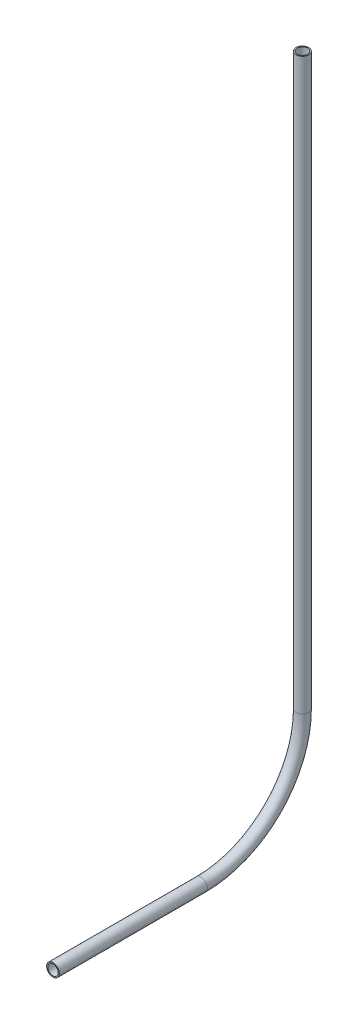
from build123d import *

# Parameters (mm, degrees)
SKETCH11_R                = 3.175
SKETCH11_R_2              = 2.6162
PIPE_0_5_SCH_40_1_DEPTH   = 74.183620327
SKETCH11_ON_SEGMENT_2_R   = 3.175
SKETCH11_ON_SEGMENT_2_R_2 = 2.6162
PIPE_0_5_SCH_40_1_2_ANGLE = 90
SKETCH11_ON_SEGMENT_3_R   = 3.175
SKETCH11_ON_SEGMENT_3_R_2 = 2.6162
PIPE_0_5_SCH_40_1_3_DEPTH = 285.339325207


with BuildPart() as part:
    # Sketch11 → Pipe 0.5 SCH 40(1) (new body)
    with BuildSketch(Plane(origin=(0, 164.683893963, 132.104570697), x_dir=(0, 1, 0), z_dir=(0, 0, -1))):
        Circle(SKETCH11_R)
        Circle(SKETCH11_R_2, mode=Mode.SUBTRACT)
    extrude(amount=PIPE_0_5_SCH_40_1_DEPTH)


with BuildPart() as body_2:
    # Sketch11 on segment 2 (carried to the start of arc 2) → Pipe 0.5 SCH 40_1 2 (revolve)
    with BuildSketch(Plane(origin=(0, 164.683893963, 57.920950369), x_dir=(0, 1, 0), z_dir=(0, 0, -1))):
        Circle(SKETCH11_ON_SEGMENT_2_R)
        Circle(SKETCH11_ON_SEGMENT_2_R_2, mode=Mode.SUBTRACT)
    revolve(axis=Axis((0, 215.483893963, 57.920950369), (1, 0, 0)), revolution_arc=PIPE_0_5_SCH_40_1_2_ANGLE)


with BuildPart() as body_3:
    # Sketch11 on segment 3 (carried to segment 3) → Pipe 0.5 SCH 40_1 3 (new body)
    with BuildSketch(Plane(origin=(0, 215.483893963, 7.120950369), x_dir=(0, 0, 1), z_dir=(0, 1, 0))):
        Circle(SKETCH11_ON_SEGMENT_3_R)
        Circle(SKETCH11_ON_SEGMENT_3_R_2, mode=Mode.SUBTRACT)
    extrude(amount=PIPE_0_5_SCH_40_1_3_DEPTH)


solid = Compound([part.part, body_2.part, body_3.part])
